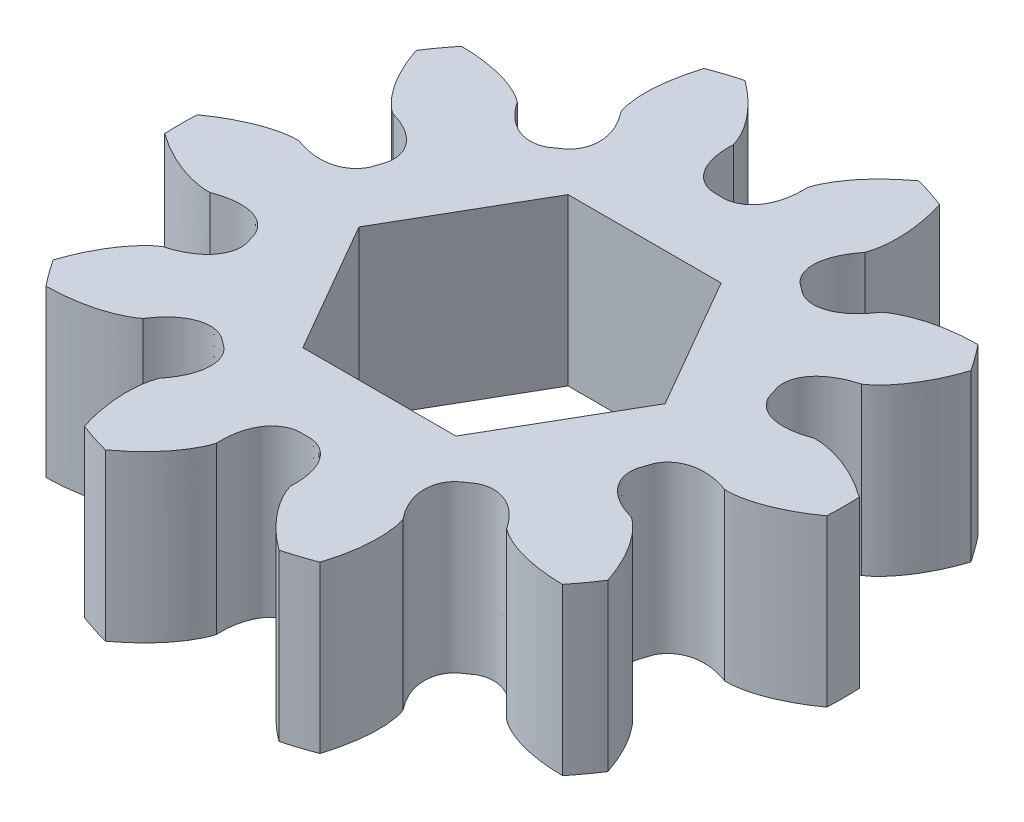
from build123d import *

# Parameters (mm, degrees)
BOSS_EXTRUDE1_DEPTH = 3


with BuildPart() as part:
    # Sketch1 → Boss-Extrude1 (new body)
    with BuildSketch(Plane(origin=(0, 0, 0), x_dir=(1, 0, 0), z_dir=(0, 1, 0))):
        with BuildLine():
            ThreePointArc((-2.131306836, -5.60870138), (-1.854101966, -5.706339098), (-1.572448505, -5.790285459))
            add(Edge.make_bspline(
                [(-1.572448505, -5.790285459), (-1.524121757, -5.753776421), (-1.427468014, -5.680758158), (-1.29005992, -5.561733251), (-1.159069112, -5.435753819), (-1.036126032, -5.301847985), (-0.92251263, -5.159932716), (-0.837301737, -5.034588255), (-0.776335293, -4.929887877), (-0.735125884, -4.848929659), (-0.698268351, -4.765746753), (-0.680638314, -4.707778502), (-0.671824783, -4.678799267)],
                knots=[0, 0, 0, 0, 0.010251706, 0.020503464, 0.030755047, 0.041006321, 0.051257106, 0.061507029, 0.066633012, 0.071758798, 0.07688417, 0.082007812, 0.082007812, 0.082007812, 0.082007812], degree=3, weights=[1, 1, 1, 1, 1, 1, 1, 1, 1, 1, 1, 1, 1]))
            add(Edge.make_bspline(
                [(-0.671824783, -4.678799267), (-0.672788438, -4.651496326), (-0.674715723, -4.596891171), (-0.67266211, -4.514929148), (-0.666126837, -4.433177326), (-0.653115793, -4.352246289), (-0.637164096, -4.271797271), (-0.612712294, -4.193474838), (-0.58299038, -4.117042318), (-0.545673731, -4.043909177), (-0.500291897, -3.975487721), (-0.447276365, -3.912783717), (-0.386261642, -3.857704877), (-0.317525574, -3.812703152), (-0.243061735, -3.777838125), (-0.176887172, -3.760110426), (-0.122948454, -3.751154668), (-0.068263798, -3.749181842), (0, -3.750545471), (0.068263798, -3.749181842), (0.122948454, -3.751154668), (0.176887172, -3.760110426), (0.243061735, -3.777838125), (0.317525574, -3.812703152), (0.386261642, -3.857704877), (0.447276365, -3.912783717), (0.500291897, -3.975487721), (0.545673731, -4.043909177), (0.58299038, -4.117042318), (0.612712294, -4.193474838), (0.637164096, -4.271797271), (0.653115793, -4.352246289), (0.666126837, -4.433177326), (0.67266211, -4.514929148), (0.674715723, -4.596891171), (0.672788438, -4.651496326), (0.671824783, -4.678799267)],
                knots=[0, 0, 0, 0, 0.003643402, 0.007286706, 0.010929975, 0.01457286, 0.01821558, 0.021858686, 0.025500936, 0.029144127, 0.032787024, 0.036428762, 0.040069815, 0.043709849, 0.04734977, 0.050988094, 0.052810356, 0.054631699, 0.058275045, 0.061918391, 0.063739733, 0.065561995, 0.069200319, 0.07284024, 0.076480275, 0.080121327, 0.083763065, 0.087405962, 0.091049153, 0.094691403, 0.098334509, 0.101977229, 0.105620114, 0.109263383, 0.112906688, 0.116550089, 0.116550089, 0.116550089, 0.116550089], degree=3, weights=[1, 1, 1, 1, 1, 1, 1, 1, 1, 1, 1, 1, 1, 1, 1, 1, 1, 1, 1, 1, 1, 1, 1, 1, 1, 1, 1, 1, 1, 1, 1, 1, 1, 1, 1, 1, 1]))
            add(Edge.make_bspline(
                [(0.671824783, -4.678799267), (0.680638314, -4.707778502), (0.698268351, -4.765746753), (0.735125884, -4.848929659), (0.776335293, -4.929887877), (0.837301737, -5.034588255), (0.92251263, -5.159932716), (1.036126032, -5.301847985), (1.159069112, -5.435753819), (1.29005992, -5.561733251), (1.427468014, -5.680758158), (1.524121757, -5.753776421), (1.572448505, -5.790285459)],
                knots=[0, 0, 0, 0, 0.002373455, 0.004747711, 0.007122158, 0.009496697, 0.014244829, 0.01899336, 0.023742117, 0.028491018, 0.03324, 0.037988957, 0.037988957, 0.037988957, 0.037988957], degree=3, weights=[1, 1, 1, 1, 1, 1, 1, 1, 1, 1, 1, 1, 1]))
            ThreePointArc((1.572448505, -5.790285459), (1.854101966, -5.706339098), (2.131306836, -5.60870138))
            add(Edge.make_bspline(
                [(2.131306836, -5.60870138), (2.148944522, -5.550759198), (2.184219984, -5.434874537), (2.225424383, -5.257814913), (2.25734932, -5.078900947), (2.278104487, -4.898304722), (2.286603958, -4.716712576), (2.281865393, -4.565221071), (2.269646944, -4.444681509), (2.25540001, -4.354962652), (2.236324695, -4.266001953), (2.216514811, -4.208741977), (2.206611541, -4.180116819)],
                knots=[0, 0, 0, 0, 0.018166013, 0.036332118, 0.054497913, 0.072663161, 0.090827541, 0.108990394, 0.11807363, 0.127156519, 0.136238672, 0.145317761, 0.145317761, 0.145317761, 0.145317761], degree=3, weights=[1, 1, 1, 1, 1, 1, 1, 1, 1, 1, 1, 1, 1]))
            add(Edge.make_bspline(
                [(2.206611541, -4.180116819), (2.189783662, -4.158594699), (2.156128351, -4.11555103), (2.10961369, -4.048035277), (2.066848322, -3.978055327), (2.029804408, -3.904933043), (1.995422855, -3.830472247), (1.969168007, -3.75273566), (1.948287632, -3.673430349), (1.935490854, -3.592330219), (1.931988406, -3.510301326), (1.938022384, -3.428410974), (1.955009802, -3.347987702), (1.984167098, -3.271178494), (2.023916461, -3.199203349), (2.067032727, -3.145964907), (2.105406004, -3.107015163), (2.148487222, -3.073276279), (2.204515316, -3.034255025), (2.258940368, -2.993027372), (2.304340782, -2.962480587), (2.353242184, -2.938021565), (2.41719861, -2.913467142), (2.49793427, -2.897904795), (2.579994267, -2.893909908), (2.661730745, -2.902606072), (2.7414777, -2.922172928), (2.818409497, -2.950852276), (2.891585883, -2.988084054), (2.960557324, -3.032449159), (3.026376018, -3.08144093), (3.086567959, -3.137149381), (3.144664185, -3.194976265), (3.198003847, -3.257273541), (3.247841323, -3.322375128), (3.278378222, -3.367684455), (3.293646874, -3.39033942)],
                knots=[0, 0, 0, 0, 0.008194405, 0.016388591, 0.024582696, 0.03277594, 0.040968812, 0.04916255, 0.057354364, 0.065548295, 0.073741565, 0.081932227, 0.090121349, 0.09830818, 0.106494756, 0.114677741, 0.118776206, 0.122872602, 0.131066881, 0.139261161, 0.143357557, 0.147456021, 0.155639006, 0.163825582, 0.172012413, 0.180201535, 0.188392198, 0.196585467, 0.204779398, 0.212971212, 0.221164951, 0.229357823, 0.237551066, 0.245745171, 0.253939358, 0.262133762, 0.262133762, 0.262133762, 0.262133762], degree=3, weights=[1, 1, 1, 1, 1, 1, 1, 1, 1, 1, 1, 1, 1, 1, 1, 1, 1, 1, 1, 1, 1, 1, 1, 1, 1, 1, 1, 1, 1, 1, 1, 1, 1, 1, 1, 1, 1]))
            add(Edge.make_bspline(
                [(3.293646874, -3.39033942), (3.317810738, -3.408603651), (3.36614662, -3.445138275), (3.444858677, -3.490770346), (3.525783835, -3.532044637), (3.636648062, -3.580913845), (3.779260749, -3.632233938), (3.954591624, -3.68026552), (4.132762539, -3.716333486), (4.312785181, -3.741258522), (4.493911749, -3.756785244), (4.615025328, -3.759046615), (4.675581963, -3.760177297)],
                knots=[0, 0, 0, 0, 0.009079089, 0.018161243, 0.027244131, 0.036327367, 0.05449022, 0.072654601, 0.090819848, 0.108985643, 0.127151749, 0.145317761, 0.145317761, 0.145317761, 0.145317761], degree=3, weights=[1, 1, 1, 1, 1, 1, 1, 1, 1, 1, 1, 1, 1]))
            ThreePointArc((4.675581963, -3.760177297), (4.854101966, -3.526711514), (5.020975406, -3.284784006))
            add(Edge.make_bspline(
                [(5.020975406, -3.284784006), (5.001187034, -3.227540624), (4.961610188, -3.113053568), (4.890872211, -2.945589986), (4.811537037, -2.782080539), (4.722176522, -2.623775544), (4.622315553, -2.471868547), (4.529437501, -2.352094604), (4.448701191, -2.261757874), (4.384439758, -2.197547932), (4.316717717, -2.136789403), (4.267034616, -2.102109067), (4.242197256, -2.084771824)],
                knots=[0, 0, 0, 0, 0.018166013, 0.036332118, 0.054497913, 0.072663161, 0.090827541, 0.108990394, 0.11807363, 0.127156519, 0.136238672, 0.145317761, 0.145317761, 0.145317761, 0.145317761], degree=3, weights=[1, 1, 1, 1, 1, 1, 1, 1, 1, 1, 1, 1, 1]))
            add(Edge.make_bspline(
                [(4.242197256, -2.084771824), (4.215932831, -2.077251242), (4.163404679, -2.062210278), (4.086088763, -2.034929518), (4.010357671, -2.003451402), (3.937408315, -1.966068098), (3.865826097, -1.926037018), (3.798893059, -1.87857901), (3.735385989, -1.826692843), (3.677363718, -1.768603217), (3.626314804, -1.704299135), (3.583062453, -1.634501765), (3.54953395, -1.559453018), (3.527975379, -1.480174835), (3.51782736, -1.39858163), (3.521416381, -1.33016772), (3.529566929, -1.27610147), (3.544589148, -1.223483634), (3.56698071, -1.158982289), (3.586778496, -1.093638174), (3.605553252, -1.042239612), (3.630738665, -0.993708325), (3.668047774, -0.936250736), (3.724216976, -0.876205302), (3.788256773, -0.824739715), (3.859494449, -0.783731563), (3.935512201, -0.752687398), (4.01460863, -0.730670102), (4.095693859, -0.717779242), (4.177570082, -0.71313097), (4.259615165, -0.714078888), (4.341056073, -0.723768037), (4.422046697, -0.736402864), (4.50181681, -0.755450152), (4.580401928, -0.778824708), (4.631738953, -0.797531586), (4.657407806, -0.806885149)],
                knots=[0, 0, 0, 0, 0.008194405, 0.016388591, 0.024582696, 0.03277594, 0.040968812, 0.04916255, 0.057354364, 0.065548295, 0.073741565, 0.081932227, 0.090121349, 0.09830818, 0.106494756, 0.114677741, 0.118776206, 0.122872602, 0.131066881, 0.139261161, 0.143357557, 0.147456021, 0.155639006, 0.163825582, 0.172012413, 0.180201535, 0.188392198, 0.196585467, 0.204779398, 0.212971212, 0.221164951, 0.229357823, 0.237551066, 0.245745171, 0.253939358, 0.262133762, 0.262133762, 0.262133762, 0.262133762], degree=3, weights=[1, 1, 1, 1, 1, 1, 1, 1, 1, 1, 1, 1, 1, 1, 1, 1, 1, 1, 1, 1, 1, 1, 1, 1, 1, 1, 1, 1, 1, 1, 1, 1, 1, 1, 1, 1, 1]))
            add(Edge.make_bspline(
                [(4.657407806, -0.806885149), (4.687692228, -0.807458059), (4.748271292, -0.808604072), (4.838772541, -0.799255407), (4.928502789, -0.785080395), (5.046918433, -0.759452057), (5.192459714, -0.717145251), (5.362537627, -0.652946714), (5.527881144, -0.577400075), (5.688173089, -0.491750199), (5.843833939, -0.397848055), (5.943146083, -0.328488767), (5.992802028, -0.293809212)],
                knots=[0, 0, 0, 0, 0.009079089, 0.018161243, 0.027244131, 0.036327367, 0.05449022, 0.072654601, 0.090819848, 0.108985643, 0.127151749, 0.145317761, 0.145317761, 0.145317761, 0.145317761], degree=3, weights=[1, 1, 1, 1, 1, 1, 1, 1, 1, 1, 1, 1, 1]))
            ThreePointArc((5.992802028, -0.293809212), (6, 0), (5.992802028, 0.293809212))
            add(Edge.make_bspline(
                [(5.992802028, 0.293809212), (5.943146083, 0.328488767), (5.843833939, 0.397848055), (5.688173089, 0.491750199), (5.527881144, 0.577400075), (5.362537627, 0.652946714), (5.192459714, 0.717145251), (5.046918433, 0.759452057), (4.928502789, 0.785080395), (4.838772541, 0.799255407), (4.748271292, 0.808604072), (4.687692228, 0.807458059), (4.657407806, 0.806885149)],
                knots=[0, 0, 0, 0, 0.018166013, 0.036332118, 0.054497913, 0.072663161, 0.090827541, 0.108990394, 0.11807363, 0.127156519, 0.136238672, 0.145317761, 0.145317761, 0.145317761, 0.145317761], degree=3, weights=[1, 1, 1, 1, 1, 1, 1, 1, 1, 1, 1, 1, 1]))
            add(Edge.make_bspline(
                [(4.657407806, 0.806885149), (4.631738953, 0.797531586), (4.580401928, 0.778824708), (4.50181681, 0.755450152), (4.422046697, 0.736402864), (4.341056073, 0.723768037), (4.259615165, 0.714078888), (4.177570082, 0.71313097), (4.095693859, 0.717779242), (4.01460863, 0.730670102), (3.935512201, 0.752687398), (3.859494449, 0.783731563), (3.788256773, 0.824739715), (3.724216976, 0.876205302), (3.668047774, 0.936250736), (3.630738665, 0.993708325), (3.605553252, 1.042239612), (3.586778496, 1.093638174), (3.56698071, 1.158982289), (3.544589148, 1.223483634), (3.529566929, 1.27610147), (3.521416381, 1.33016772), (3.51782736, 1.39858163), (3.527975379, 1.480174835), (3.54953395, 1.559453018), (3.583062453, 1.634501765), (3.626314804, 1.704299135), (3.677363718, 1.768603217), (3.735385989, 1.826692843), (3.798893059, 1.87857901), (3.865826097, 1.926037018), (3.937408315, 1.966068098), (4.010357671, 2.003451402), (4.086088763, 2.034929518), (4.163404679, 2.062210278), (4.215932831, 2.077251242), (4.242197256, 2.084771824)],
                knots=[0, 0, 0, 0, 0.008194405, 0.016388591, 0.024582696, 0.03277594, 0.040968812, 0.04916255, 0.057354364, 0.065548295, 0.073741565, 0.081932227, 0.090121349, 0.09830818, 0.106494756, 0.114677741, 0.118776206, 0.122872602, 0.131066881, 0.139261161, 0.143357557, 0.147456021, 0.155639006, 0.163825582, 0.172012413, 0.180201535, 0.188392198, 0.196585467, 0.204779398, 0.212971212, 0.221164951, 0.229357823, 0.237551066, 0.245745171, 0.253939358, 0.262133762, 0.262133762, 0.262133762, 0.262133762], degree=3, weights=[1, 1, 1, 1, 1, 1, 1, 1, 1, 1, 1, 1, 1, 1, 1, 1, 1, 1, 1, 1, 1, 1, 1, 1, 1, 1, 1, 1, 1, 1, 1, 1, 1, 1, 1, 1, 1]))
            add(Edge.make_bspline(
                [(4.242197256, 2.084771824), (4.267034616, 2.102109067), (4.316717717, 2.136789403), (4.384439758, 2.197547932), (4.448701191, 2.261757874), (4.529437501, 2.352094604), (4.622315553, 2.471868547), (4.722176522, 2.623775544), (4.811537037, 2.782080539), (4.890872211, 2.945589986), (4.961610188, 3.113053568), (5.001187034, 3.227540624), (5.020975406, 3.284784006)],
                knots=[0, 0, 0, 0, 0.009079089, 0.018161243, 0.027244131, 0.036327367, 0.05449022, 0.072654601, 0.090819848, 0.108985643, 0.127151749, 0.145317761, 0.145317761, 0.145317761, 0.145317761], degree=3, weights=[1, 1, 1, 1, 1, 1, 1, 1, 1, 1, 1, 1, 1]))
            ThreePointArc((5.020975406, 3.284784006), (4.854101966, 3.526711514), (4.675581963, 3.760177297))
            add(Edge.make_bspline(
                [(4.675581963, 3.760177297), (4.615025328, 3.759046615), (4.493911749, 3.756785244), (4.312785181, 3.741258522), (4.132762539, 3.716333486), (3.954591624, 3.68026552), (3.779260749, 3.632233938), (3.636648062, 3.580913845), (3.525783835, 3.532044637), (3.444858677, 3.490770346), (3.36614662, 3.445138275), (3.317810738, 3.408603651), (3.293646874, 3.39033942)],
                knots=[0, 0, 0, 0, 0.018166013, 0.036332118, 0.054497913, 0.072663161, 0.090827541, 0.108990394, 0.11807363, 0.127156519, 0.136238672, 0.145317761, 0.145317761, 0.145317761, 0.145317761], degree=3, weights=[1, 1, 1, 1, 1, 1, 1, 1, 1, 1, 1, 1, 1]))
            add(Edge.make_bspline(
                [(3.293646874, 3.39033942), (3.278378222, 3.367684455), (3.247841323, 3.322375128), (3.198003847, 3.257273541), (3.144664185, 3.194976265), (3.086567959, 3.137149381), (3.026376018, 3.08144093), (2.960557324, 3.032449159), (2.891585883, 2.988084054), (2.818409497, 2.950852276), (2.7414777, 2.922172928), (2.661730745, 2.902606072), (2.579994267, 2.893909908), (2.49793427, 2.897904795), (2.41719861, 2.913467142), (2.353242184, 2.938021565), (2.304340782, 2.962480587), (2.258940368, 2.993027372), (2.204515316, 3.034255025), (2.148487222, 3.073276279), (2.105406004, 3.107015163), (2.067032727, 3.145964907), (2.023916461, 3.199203349), (1.984167098, 3.271178494), (1.955009802, 3.347987702), (1.938022384, 3.428410974), (1.931988406, 3.510301326), (1.935490854, 3.592330219), (1.948287632, 3.673430349), (1.969168007, 3.75273566), (1.995422855, 3.830472247), (2.029804408, 3.904933043), (2.066848322, 3.978055327), (2.10961369, 4.048035277), (2.156128351, 4.11555103), (2.189783662, 4.158594699), (2.206611541, 4.180116819)],
                knots=[0, 0, 0, 0, 0.008194405, 0.016388591, 0.024582696, 0.03277594, 0.040968812, 0.04916255, 0.057354364, 0.065548295, 0.073741565, 0.081932227, 0.090121349, 0.09830818, 0.106494756, 0.114677741, 0.118776206, 0.122872602, 0.131066881, 0.139261161, 0.143357557, 0.147456021, 0.155639006, 0.163825582, 0.172012413, 0.180201535, 0.188392198, 0.196585467, 0.204779398, 0.212971212, 0.221164951, 0.229357823, 0.237551066, 0.245745171, 0.253939358, 0.262133762, 0.262133762, 0.262133762, 0.262133762], degree=3, weights=[1, 1, 1, 1, 1, 1, 1, 1, 1, 1, 1, 1, 1, 1, 1, 1, 1, 1, 1, 1, 1, 1, 1, 1, 1, 1, 1, 1, 1, 1, 1, 1, 1, 1, 1, 1, 1]))
            add(Edge.make_bspline(
                [(2.206611541, 4.180116819), (2.216514811, 4.208741977), (2.236324695, 4.266001953), (2.25540001, 4.354962652), (2.269646944, 4.444681509), (2.281865393, 4.565221071), (2.286603958, 4.716712576), (2.278104487, 4.898304722), (2.25734932, 5.078900947), (2.225424383, 5.257814913), (2.184219984, 5.434874537), (2.148944522, 5.550759198), (2.131306836, 5.60870138)],
                knots=[0, 0, 0, 0, 0.009079089, 0.018161243, 0.027244131, 0.036327367, 0.05449022, 0.072654601, 0.090819848, 0.108985643, 0.127151749, 0.145317761, 0.145317761, 0.145317761, 0.145317761], degree=3, weights=[1, 1, 1, 1, 1, 1, 1, 1, 1, 1, 1, 1, 1]))
            ThreePointArc((2.131306836, 5.60870138), (1.854101966, 5.706339098), (1.572448505, 5.790285459))
            add(Edge.make_bspline(
                [(1.572448505, 5.790285459), (1.524121757, 5.753776421), (1.427468014, 5.680758158), (1.29005992, 5.561733251), (1.159069112, 5.435753819), (1.036126032, 5.301847985), (0.92251263, 5.159932716), (0.837301737, 5.034588255), (0.776335293, 4.929887877), (0.735125884, 4.848929659), (0.698268351, 4.765746753), (0.680638314, 4.707778502), (0.671824783, 4.678799267)],
                knots=[0, 0, 0, 0, 0.018166013, 0.036332118, 0.054497913, 0.072663161, 0.090827541, 0.108990394, 0.11807363, 0.127156519, 0.136238672, 0.145317761, 0.145317761, 0.145317761, 0.145317761], degree=3, weights=[1, 1, 1, 1, 1, 1, 1, 1, 1, 1, 1, 1, 1]))
            add(Edge.make_bspline(
                [(0.671824783, 4.678799267), (0.672788438, 4.651496326), (0.674715723, 4.596891171), (0.67266211, 4.514929148), (0.666126837, 4.433177326), (0.653115793, 4.352246289), (0.637164096, 4.271797271), (0.612712294, 4.193474838), (0.58299038, 4.117042318), (0.545673731, 4.043909177), (0.500291897, 3.975487721), (0.447276365, 3.912783717), (0.386261642, 3.857704877), (0.317525574, 3.812703152), (0.243061735, 3.777838125), (0.176887172, 3.760110426), (0.122948454, 3.751154668), (0.068263798, 3.749181842), (0, 3.750545471), (-0.068263798, 3.749181842), (-0.122948454, 3.751154668), (-0.176887172, 3.760110426), (-0.243061735, 3.777838125), (-0.317525574, 3.812703152), (-0.386261642, 3.857704877), (-0.447276365, 3.912783717), (-0.500291897, 3.975487721), (-0.545673731, 4.043909177), (-0.58299038, 4.117042318), (-0.612712294, 4.193474838), (-0.637164096, 4.271797271), (-0.653115793, 4.352246289), (-0.666126837, 4.433177326), (-0.67266211, 4.514929148), (-0.674715723, 4.596891171), (-0.672788438, 4.651496326), (-0.671824783, 4.678799267)],
                knots=[0, 0, 0, 0, 0.008194405, 0.016388591, 0.024582696, 0.03277594, 0.040968812, 0.04916255, 0.057354364, 0.065548295, 0.073741565, 0.081932227, 0.090121349, 0.09830818, 0.106494756, 0.114677741, 0.118776206, 0.122872602, 0.131066881, 0.139261161, 0.143357557, 0.147456021, 0.155639006, 0.163825582, 0.172012413, 0.180201535, 0.188392198, 0.196585467, 0.204779398, 0.212971212, 0.221164951, 0.229357823, 0.237551066, 0.245745171, 0.253939358, 0.262133762, 0.262133762, 0.262133762, 0.262133762], degree=3, weights=[1, 1, 1, 1, 1, 1, 1, 1, 1, 1, 1, 1, 1, 1, 1, 1, 1, 1, 1, 1, 1, 1, 1, 1, 1, 1, 1, 1, 1, 1, 1, 1, 1, 1, 1, 1, 1]))
            add(Edge.make_bspline(
                [(-0.671824783, 4.678799267), (-0.680638314, 4.707778502), (-0.698268351, 4.765746753), (-0.735125884, 4.848929659), (-0.776335293, 4.929887877), (-0.837301737, 5.034588255), (-0.92251263, 5.159932716), (-1.036126032, 5.301847985), (-1.159069112, 5.435753819), (-1.29005992, 5.561733251), (-1.427468014, 5.680758158), (-1.524121757, 5.753776421), (-1.572448505, 5.790285459)],
                knots=[0, 0, 0, 0, 0.009079089, 0.018161243, 0.027244131, 0.036327367, 0.05449022, 0.072654601, 0.090819848, 0.108985643, 0.127151749, 0.145317761, 0.145317761, 0.145317761, 0.145317761], degree=3, weights=[1, 1, 1, 1, 1, 1, 1, 1, 1, 1, 1, 1, 1]))
            ThreePointArc((-1.572448505, 5.790285459), (-1.854101966, 5.706339098), (-2.131306836, 5.60870138))
            add(Edge.make_bspline(
                [(-2.131306836, 5.60870138), (-2.148944522, 5.550759198), (-2.184219984, 5.434874537), (-2.225424383, 5.257814913), (-2.25734932, 5.078900947), (-2.278104487, 4.898304722), (-2.286603958, 4.716712576), (-2.281865393, 4.565221071), (-2.269646944, 4.444681509), (-2.25540001, 4.354962652), (-2.236324695, 4.266001953), (-2.216514811, 4.208741977), (-2.206611541, 4.180116819)],
                knots=[0, 0, 0, 0, 0.018166013, 0.036332118, 0.054497913, 0.072663161, 0.090827541, 0.108990394, 0.11807363, 0.127156519, 0.136238672, 0.145317761, 0.145317761, 0.145317761, 0.145317761], degree=3, weights=[1, 1, 1, 1, 1, 1, 1, 1, 1, 1, 1, 1, 1]))
            add(Edge.make_bspline(
                [(-2.206611541, 4.180116819), (-2.189783662, 4.158594699), (-2.156128351, 4.11555103), (-2.10961369, 4.048035277), (-2.066848322, 3.978055327), (-2.029804408, 3.904933043), (-1.995422855, 3.830472247), (-1.969168007, 3.75273566), (-1.948287632, 3.673430349), (-1.935490854, 3.592330219), (-1.931988406, 3.510301326), (-1.938022384, 3.428410974), (-1.955009802, 3.347987702), (-1.984167098, 3.271178494), (-2.023916461, 3.199203349), (-2.067032727, 3.145964907), (-2.105406004, 3.107015163), (-2.148487222, 3.073276279), (-2.204515316, 3.034255025), (-2.258940368, 2.993027372), (-2.304340782, 2.962480587), (-2.353242184, 2.938021565), (-2.41719861, 2.913467142), (-2.49793427, 2.897904795), (-2.579994267, 2.893909908), (-2.661730745, 2.902606072), (-2.7414777, 2.922172928), (-2.818409497, 2.950852276), (-2.891585883, 2.988084054), (-2.960557324, 3.032449159), (-3.026376018, 3.08144093), (-3.086567959, 3.137149381), (-3.144664185, 3.194976265), (-3.198003847, 3.257273541), (-3.247841323, 3.322375128), (-3.278378222, 3.367684455), (-3.293646874, 3.39033942)],
                knots=[0, 0, 0, 0, 0.008194405, 0.016388591, 0.024582696, 0.03277594, 0.040968812, 0.04916255, 0.057354364, 0.065548295, 0.073741565, 0.081932227, 0.090121349, 0.09830818, 0.106494756, 0.114677741, 0.118776206, 0.122872602, 0.131066881, 0.139261161, 0.143357557, 0.147456021, 0.155639006, 0.163825582, 0.172012413, 0.180201535, 0.188392198, 0.196585467, 0.204779398, 0.212971212, 0.221164951, 0.229357823, 0.237551066, 0.245745171, 0.253939358, 0.262133762, 0.262133762, 0.262133762, 0.262133762], degree=3, weights=[1, 1, 1, 1, 1, 1, 1, 1, 1, 1, 1, 1, 1, 1, 1, 1, 1, 1, 1, 1, 1, 1, 1, 1, 1, 1, 1, 1, 1, 1, 1, 1, 1, 1, 1, 1, 1]))
            add(Edge.make_bspline(
                [(-3.293646874, 3.39033942), (-3.317810738, 3.408603651), (-3.36614662, 3.445138275), (-3.444858677, 3.490770346), (-3.525783835, 3.532044637), (-3.636648062, 3.580913845), (-3.779260749, 3.632233938), (-3.954591624, 3.68026552), (-4.132762539, 3.716333486), (-4.312785181, 3.741258522), (-4.493911749, 3.756785244), (-4.615025328, 3.759046615), (-4.675581963, 3.760177297)],
                knots=[0, 0, 0, 0, 0.009079089, 0.018161243, 0.027244131, 0.036327367, 0.05449022, 0.072654601, 0.090819848, 0.108985643, 0.127151749, 0.145317761, 0.145317761, 0.145317761, 0.145317761], degree=3, weights=[1, 1, 1, 1, 1, 1, 1, 1, 1, 1, 1, 1, 1]))
            ThreePointArc((-4.675581963, 3.760177297), (-4.854101966, 3.526711514), (-5.020975406, 3.284784006))
            add(Edge.make_bspline(
                [(-5.020975406, 3.284784006), (-5.001187034, 3.227540624), (-4.961610188, 3.113053568), (-4.890872211, 2.945589986), (-4.811537037, 2.782080539), (-4.722176522, 2.623775544), (-4.622315553, 2.471868547), (-4.529437501, 2.352094604), (-4.448701191, 2.261757874), (-4.384439758, 2.197547932), (-4.316717717, 2.136789403), (-4.267034616, 2.102109067), (-4.242197256, 2.084771824)],
                knots=[0, 0, 0, 0, 0.018166013, 0.036332118, 0.054497913, 0.072663161, 0.090827541, 0.108990394, 0.11807363, 0.127156519, 0.136238672, 0.145317761, 0.145317761, 0.145317761, 0.145317761], degree=3, weights=[1, 1, 1, 1, 1, 1, 1, 1, 1, 1, 1, 1, 1]))
            add(Edge.make_bspline(
                [(-4.242197256, 2.084771824), (-4.215932831, 2.077251242), (-4.163404679, 2.062210278), (-4.086088763, 2.034929518), (-4.010357671, 2.003451402), (-3.937408315, 1.966068098), (-3.865826097, 1.926037018), (-3.798893059, 1.87857901), (-3.735385989, 1.826692843), (-3.677363718, 1.768603217), (-3.626314804, 1.704299135), (-3.583062453, 1.634501765), (-3.54953395, 1.559453018), (-3.527975379, 1.480174835), (-3.51782736, 1.39858163), (-3.521416381, 1.33016772), (-3.529566929, 1.27610147), (-3.544589148, 1.223483634), (-3.56698071, 1.158982289), (-3.586778496, 1.093638174), (-3.605553252, 1.042239612), (-3.630738665, 0.993708325), (-3.668047774, 0.936250736), (-3.724216976, 0.876205302), (-3.788256773, 0.824739715), (-3.859494449, 0.783731563), (-3.935512201, 0.752687398), (-4.01460863, 0.730670102), (-4.095693859, 0.717779242), (-4.177570082, 0.71313097), (-4.259615165, 0.714078888), (-4.341056073, 0.723768037), (-4.422046697, 0.736402864), (-4.50181681, 0.755450152), (-4.580401928, 0.778824708), (-4.631738953, 0.797531586), (-4.657407806, 0.806885149)],
                knots=[0, 0, 0, 0, 0.008194405, 0.016388591, 0.024582696, 0.03277594, 0.040968812, 0.04916255, 0.057354364, 0.065548295, 0.073741565, 0.081932227, 0.090121349, 0.09830818, 0.106494756, 0.114677741, 0.118776206, 0.122872602, 0.131066881, 0.139261161, 0.143357557, 0.147456021, 0.155639006, 0.163825582, 0.172012413, 0.180201535, 0.188392198, 0.196585467, 0.204779398, 0.212971212, 0.221164951, 0.229357823, 0.237551066, 0.245745171, 0.253939358, 0.262133762, 0.262133762, 0.262133762, 0.262133762], degree=3, weights=[1, 1, 1, 1, 1, 1, 1, 1, 1, 1, 1, 1, 1, 1, 1, 1, 1, 1, 1, 1, 1, 1, 1, 1, 1, 1, 1, 1, 1, 1, 1, 1, 1, 1, 1, 1, 1]))
            add(Edge.make_bspline(
                [(-4.657407806, 0.806885149), (-4.687692228, 0.807458059), (-4.748271292, 0.808604072), (-4.838772541, 0.799255407), (-4.928502789, 0.785080395), (-5.046918433, 0.759452057), (-5.192459714, 0.717145251), (-5.362537627, 0.652946714), (-5.527881144, 0.577400075), (-5.688173089, 0.491750199), (-5.843833939, 0.397848055), (-5.943146083, 0.328488767), (-5.992802028, 0.293809212)],
                knots=[0, 0, 0, 0, 0.009079089, 0.018161243, 0.027244131, 0.036327367, 0.05449022, 0.072654601, 0.090819848, 0.108985643, 0.127151749, 0.145317761, 0.145317761, 0.145317761, 0.145317761], degree=3, weights=[1, 1, 1, 1, 1, 1, 1, 1, 1, 1, 1, 1, 1]))
            ThreePointArc((-5.992802028, 0.293809212), (-6, 0), (-5.992802028, -0.293809212))
            add(Edge.make_bspline(
                [(-5.992802028, -0.293809212), (-5.943146083, -0.328488767), (-5.843833939, -0.397848055), (-5.688173089, -0.491750199), (-5.527881144, -0.577400075), (-5.362537627, -0.652946714), (-5.192459714, -0.717145251), (-5.046918433, -0.759452057), (-4.928502789, -0.785080395), (-4.838772541, -0.799255407), (-4.748271292, -0.808604072), (-4.687692228, -0.807458059), (-4.657407806, -0.806885149)],
                knots=[0, 0, 0, 0, 0.018166013, 0.036332118, 0.054497913, 0.072663161, 0.090827541, 0.108990394, 0.11807363, 0.127156519, 0.136238672, 0.145317761, 0.145317761, 0.145317761, 0.145317761], degree=3, weights=[1, 1, 1, 1, 1, 1, 1, 1, 1, 1, 1, 1, 1]))
            add(Edge.make_bspline(
                [(-4.657407806, -0.806885149), (-4.631738953, -0.797531586), (-4.580401928, -0.778824708), (-4.50181681, -0.755450152), (-4.422046697, -0.736402864), (-4.341056073, -0.723768037), (-4.259615165, -0.714078888), (-4.177570082, -0.71313097), (-4.095693859, -0.717779242), (-4.01460863, -0.730670102), (-3.935512201, -0.752687398), (-3.859494449, -0.783731563), (-3.788256773, -0.824739715), (-3.724216976, -0.876205302), (-3.668047774, -0.936250736), (-3.630738665, -0.993708325), (-3.605553252, -1.042239612), (-3.586778496, -1.093638174), (-3.56698071, -1.158982289), (-3.544589148, -1.223483634), (-3.529566929, -1.27610147), (-3.521416381, -1.33016772), (-3.51782736, -1.39858163), (-3.527975379, -1.480174835), (-3.54953395, -1.559453018), (-3.583062453, -1.634501765), (-3.626314804, -1.704299135), (-3.677363718, -1.768603217), (-3.735385989, -1.826692843), (-3.798893059, -1.87857901), (-3.865826097, -1.926037018), (-3.937408315, -1.966068098), (-4.010357671, -2.003451402), (-4.086088763, -2.034929518), (-4.163404679, -2.062210278), (-4.215932831, -2.077251242), (-4.242197256, -2.084771824)],
                knots=[0, 0, 0, 0, 0.008194405, 0.016388591, 0.024582696, 0.03277594, 0.040968812, 0.04916255, 0.057354364, 0.065548295, 0.073741565, 0.081932227, 0.090121349, 0.09830818, 0.106494756, 0.114677741, 0.118776206, 0.122872602, 0.131066881, 0.139261161, 0.143357557, 0.147456021, 0.155639006, 0.163825582, 0.172012413, 0.180201535, 0.188392198, 0.196585467, 0.204779398, 0.212971212, 0.221164951, 0.229357823, 0.237551066, 0.245745171, 0.253939358, 0.262133762, 0.262133762, 0.262133762, 0.262133762], degree=3, weights=[1, 1, 1, 1, 1, 1, 1, 1, 1, 1, 1, 1, 1, 1, 1, 1, 1, 1, 1, 1, 1, 1, 1, 1, 1, 1, 1, 1, 1, 1, 1, 1, 1, 1, 1, 1, 1]))
            add(Edge.make_bspline(
                [(-4.242197256, -2.084771824), (-4.267034616, -2.102109067), (-4.316717717, -2.136789403), (-4.384439758, -2.197547932), (-4.448701191, -2.261757874), (-4.529437501, -2.352094604), (-4.622315553, -2.471868547), (-4.722176522, -2.623775544), (-4.811537037, -2.782080539), (-4.890872211, -2.945589986), (-4.961610188, -3.113053568), (-5.001187034, -3.227540624), (-5.020975406, -3.284784006)],
                knots=[0, 0, 0, 0, 0.009079089, 0.018161243, 0.027244131, 0.036327367, 0.05449022, 0.072654601, 0.090819848, 0.108985643, 0.127151749, 0.145317761, 0.145317761, 0.145317761, 0.145317761], degree=3, weights=[1, 1, 1, 1, 1, 1, 1, 1, 1, 1, 1, 1, 1]))
            ThreePointArc((-5.020975406, -3.284784006), (-4.854101966, -3.526711514), (-4.675581963, -3.760177297))
            add(Edge.make_bspline(
                [(-4.675581963, -3.760177297), (-4.615025328, -3.759046615), (-4.493911749, -3.756785244), (-4.312785181, -3.741258522), (-4.132762539, -3.716333486), (-3.954591624, -3.68026552), (-3.779260749, -3.632233938), (-3.636648062, -3.580913845), (-3.525783835, -3.532044637), (-3.444858677, -3.490770346), (-3.36614662, -3.445138275), (-3.317810738, -3.408603651), (-3.293646874, -3.39033942)],
                knots=[0, 0, 0, 0, 0.018166013, 0.036332118, 0.054497913, 0.072663161, 0.090827541, 0.108990394, 0.11807363, 0.127156519, 0.136238672, 0.145317761, 0.145317761, 0.145317761, 0.145317761], degree=3, weights=[1, 1, 1, 1, 1, 1, 1, 1, 1, 1, 1, 1, 1]))
            add(Edge.make_bspline(
                [(-3.293646874, -3.39033942), (-3.278378222, -3.367684455), (-3.247841323, -3.322375128), (-3.198003847, -3.257273541), (-3.144664185, -3.194976265), (-3.086567959, -3.137149381), (-3.026376018, -3.08144093), (-2.960557324, -3.032449159), (-2.891585883, -2.988084054), (-2.818409497, -2.950852276), (-2.7414777, -2.922172928), (-2.661730745, -2.902606072), (-2.579994267, -2.893909908), (-2.49793427, -2.897904795), (-2.41719861, -2.913467142), (-2.353242184, -2.938021565), (-2.304340782, -2.962480587), (-2.258940368, -2.993027372), (-2.204515316, -3.034255025), (-2.148487222, -3.073276279), (-2.105406004, -3.107015163), (-2.067032727, -3.145964907), (-2.023916461, -3.199203349), (-1.984167098, -3.271178494), (-1.955009802, -3.347987702), (-1.938022384, -3.428410974), (-1.931988406, -3.510301326), (-1.935490854, -3.592330219), (-1.948287632, -3.673430349), (-1.969168007, -3.75273566), (-1.995422855, -3.830472247), (-2.029804408, -3.904933043), (-2.066848322, -3.978055327), (-2.10961369, -4.048035277), (-2.156128351, -4.11555103), (-2.189783662, -4.158594699), (-2.206611541, -4.180116819)],
                knots=[0, 0, 0, 0, 0.008194405, 0.016388591, 0.024582696, 0.03277594, 0.040968812, 0.04916255, 0.057354364, 0.065548295, 0.073741565, 0.081932227, 0.090121349, 0.09830818, 0.106494756, 0.114677741, 0.118776206, 0.122872602, 0.131066881, 0.139261161, 0.143357557, 0.147456021, 0.155639006, 0.163825582, 0.172012413, 0.180201535, 0.188392198, 0.196585467, 0.204779398, 0.212971212, 0.221164951, 0.229357823, 0.237551066, 0.245745171, 0.253939358, 0.262133762, 0.262133762, 0.262133762, 0.262133762], degree=3, weights=[1, 1, 1, 1, 1, 1, 1, 1, 1, 1, 1, 1, 1, 1, 1, 1, 1, 1, 1, 1, 1, 1, 1, 1, 1, 1, 1, 1, 1, 1, 1, 1, 1, 1, 1, 1, 1]))
            add(Edge.make_bspline(
                [(-2.206611541, -4.180116819), (-2.216514811, -4.208741977), (-2.236324695, -4.266001953), (-2.25540001, -4.354962652), (-2.269646944, -4.444681509), (-2.281865393, -4.565221071), (-2.286603958, -4.716712576), (-2.278104487, -4.898304722), (-2.25734932, -5.078900947), (-2.225424383, -5.257814913), (-2.184219984, -5.434874537), (-2.148944522, -5.550759198), (-2.131306836, -5.60870138)],
                knots=[0, 0, 0, 0, 0.009079089, 0.018161243, 0.027244131, 0.036327367, 0.05449022, 0.072654601, 0.090819848, 0.108985643, 0.127151749, 0.145317761, 0.145317761, 0.145317761, 0.145317761], degree=3, weights=[1, 1, 1, 1, 1, 1, 1, 1, 1, 1, 1, 1, 1]))
        make_face()
        Polygon((2.771281292, 0), (1.385640646, -2.4), (-1.385640646, -2.4), (-2.771281292, 0), (-1.385640646, 2.4), (1.385640646, 2.4), align=None, mode=Mode.SUBTRACT)
    extrude(amount=BOSS_EXTRUDE1_DEPTH)


solid = part.part
